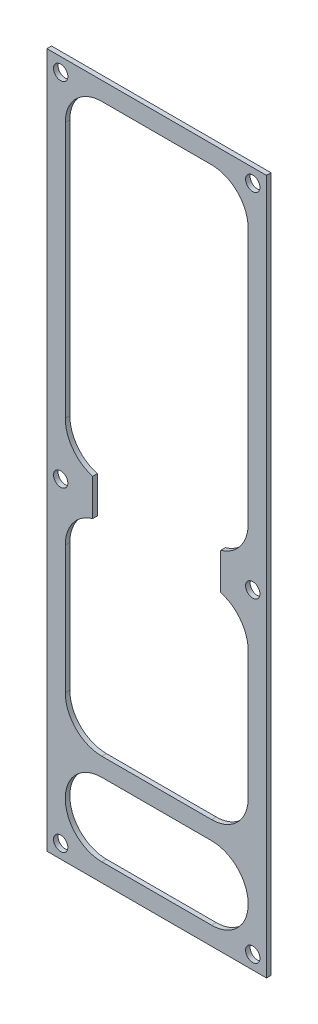
from build123d import *

# Parameters (mm, degrees)
SKETCH1_W           = 76.2
SKETCH1_H           = 241.3
BOSS_EXTRUDE1_DEPTH = 1.5875
CUT_EXTRUDE1_DEPTH  = 1.5875
SKETCH3_R           = 2.4892
CUT_EXTRUDE2_DEPTH  = 1.5875


with BuildPart() as part:
    # Sketch1 → Boss-Extrude1 (new body)
    with BuildSketch(Plane.XY):
        with Locations((38.1, -120.65)):
            Rectangle(SKETCH1_W, SKETCH1_H)
    extrude(amount=BOSS_EXTRUDE1_DEPTH)

    # Sketch2 → Cut-Extrude1 (cut)
    with BuildSketch(Plane.XY.offset(1.5875)):
        with BuildLine():
            Line((19.05, -6.35), (57.15, -6.35))
            ThreePointArc((57.15, -6.35), (66.130256121, -10.069743879), (69.85, -19.05))
            Line((69.85, -19.05), (69.85, -107.95))
            ThreePointArc((69.85, -107.95), (67.204166667, -115.8875), (60.325, -120.65))
            Line((60.325, -120.65), (60.325, -133.35))
            ThreePointArc((60.325, -133.35), (67.204166667, -138.1125), (69.85, -146.05))
            Line((69.85, -146.05), (69.85, -190.5))
            ThreePointArc((69.85, -190.5), (66.130256121, -199.480256121), (57.15, -203.2))
            Line((57.15, -203.2), (19.05, -203.2))
            ThreePointArc((19.05, -203.2), (10.069743879, -199.480256121), (6.35, -190.5))
            Line((6.35, -190.5), (6.35, -146.05))
            ThreePointArc((6.35, -146.05), (8.995833333, -138.1125), (15.875, -133.35))
            Line((15.875, -133.35), (15.875, -120.65))
            ThreePointArc((15.875, -120.65), (8.995833333, -115.8875), (6.35, -107.95))
            Line((6.35, -107.95), (6.35, -19.05))
            ThreePointArc((6.35, -19.05), (10.069743879, -10.069743879), (19.05, -6.35))
        make_face()
        with BuildLine():
            Line((19.05, -234.95), (57.15, -234.95))
            ThreePointArc((57.15, -234.95), (69.85, -222.25), (57.15, -209.55))
            Line((57.15, -209.55), (19.05, -209.55))
            ThreePointArc((19.05, -209.55), (6.35, -222.25), (19.05, -234.95))
        make_face()
    extrude(amount=-CUT_EXTRUDE1_DEPTH, mode=Mode.SUBTRACT)

    # Sketch3 → Cut-Extrude2 (cut)
    with BuildSketch(Plane.XY.offset(1.5875)):
        with Locations((4.7625, -4.7625)):
            Circle(SKETCH3_R)
        with Locations((71.4375, -4.7625)):
            Circle(SKETCH3_R)
        with Locations((71.4375, -127)):
            Circle(SKETCH3_R)
        with Locations((4.7625, -127)):
            Circle(SKETCH3_R)
        with Locations((4.7625, -236.5375)):
            Circle(SKETCH3_R)
        with Locations((71.4375, -236.5375)):
            Circle(SKETCH3_R)
    extrude(amount=-CUT_EXTRUDE2_DEPTH, mode=Mode.SUBTRACT)


solid = part.part
